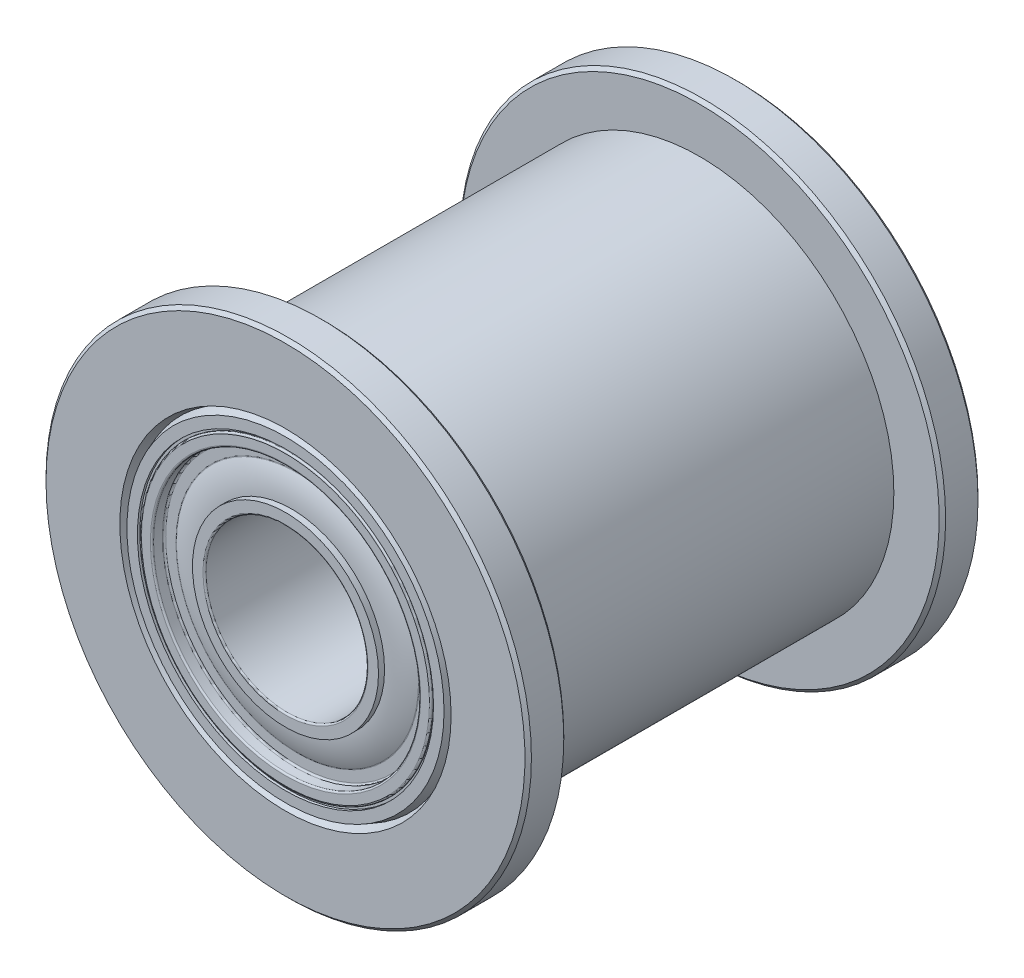
from build123d import *

# Parameters (mm, degrees)
CHAMFER1_SIZE = 0.1
FILLET2_R     = 0.05


with BuildPart() as part:
    # Sketch2 → Revolve1 (revolve)
    with BuildSketch(Plane(origin=(0, 0, 0), x_dir=(0, 0, -1), z_dir=(1, 0, 0))):
        with BuildLine():
            Line((7, 2.5), (0, 2.5))
            Line((0, 2.5), (0, 4.5))
            Line((0, 4.5), (7, 4.5))
            Line((7, 4.5), (7, 4.125))
            Line((7, 4.125), (6.625, 4.125))
            Line((6.625, 4.125), (6.625, 3.75))
            ThreePointArc((6.625, 3.75), (6.765098905, 3.322431908), (6.8125, 2.875))
            Line((6.8125, 2.875), (7, 2.875))
            Line((7, 2.875), (7, 2.5))
        make_face()
    revolve(axis=Axis((0, 0, 7), (0, 0, -1)))

    # Mirror1: part across plane


with BuildPart() as part_1:
    add(part.part)
    add(part.part.mirror(Plane.XY))

    # Fillet2
    fillet2_edges = [part_1.edges().sort_by_distance(p)[0] for p in [
        (0, -2.5, -7),
        (0, -2.5, 7),
        (0, -4.5, 7),
        (0, -4.125, 7),
        (0, -4.125, 6.625),
        (0, -3.75, 6.625),
        (0, -2.875, -7),
        (0, -3.75, -6.625),
        (0, -4.125, -7),
        (0, -4.5, -7),
    ]]
    fillet(fillet2_edges, radius=FILLET2_R)


with BuildPart() as body_2:
    # Sketch3 → Revolve2 (revolve)
    with BuildSketch(Plane(origin=(0, 0, 0), x_dir=(0, 0, -1), z_dir=(1, 0, 0))):
        Polygon((5.8, 7.5), (7, 7.5), (7, 5.118382141), (6.7, 5.00919107), (7, 4.9), (7, 4.575), (6.925, 4.575), (6.925, 4.5), (-6.925, 4.5), (-6.925, 4.575), (-7, 4.575), (-7, 4.9), (-6.7, 5.00919107), (-7, 5.118382141), (-7, 7.5), (-5.8, 7.5), (-5.8, 6), (5.8, 6), align=None)
    revolve(axis=Axis((0, 0, 7), (0, 0, -1)))

    # Chamfer1
    chamfer1_edges = [body_2.edges().sort_by_distance(p)[0] for p in [
        (0, -7.5, 5.8),
        (0, -7.5, 7),
        (0, -7.5, -7),
        (0, -7.5, -5.8),
    ]]
    chamfer(chamfer1_edges, length=CHAMFER1_SIZE)

    # Combine1: union part
    add(part_1.part)


solid = body_2.part
